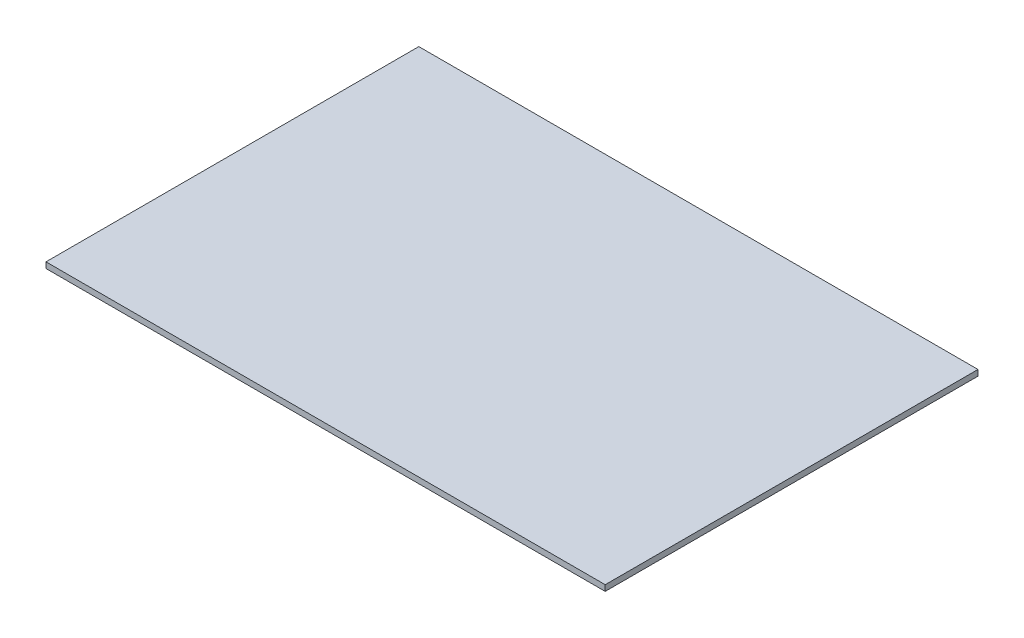
from build123d import *

# Parameters (mm, degrees)
SKETCH1_W           = 304.8
SKETCH1_H           = 203.2
BOSS_EXTRUDE1_DEPTH = 3.175


with BuildPart() as part:
    # Sketch1 → Boss-Extrude1 (new body)
    with BuildSketch(Plane(origin=(0, 0, 0), x_dir=(1, 0, 0), z_dir=(0, 1, 0))):
        Rectangle(SKETCH1_W, SKETCH1_H)
    extrude(amount=BOSS_EXTRUDE1_DEPTH)


solid = part.part
